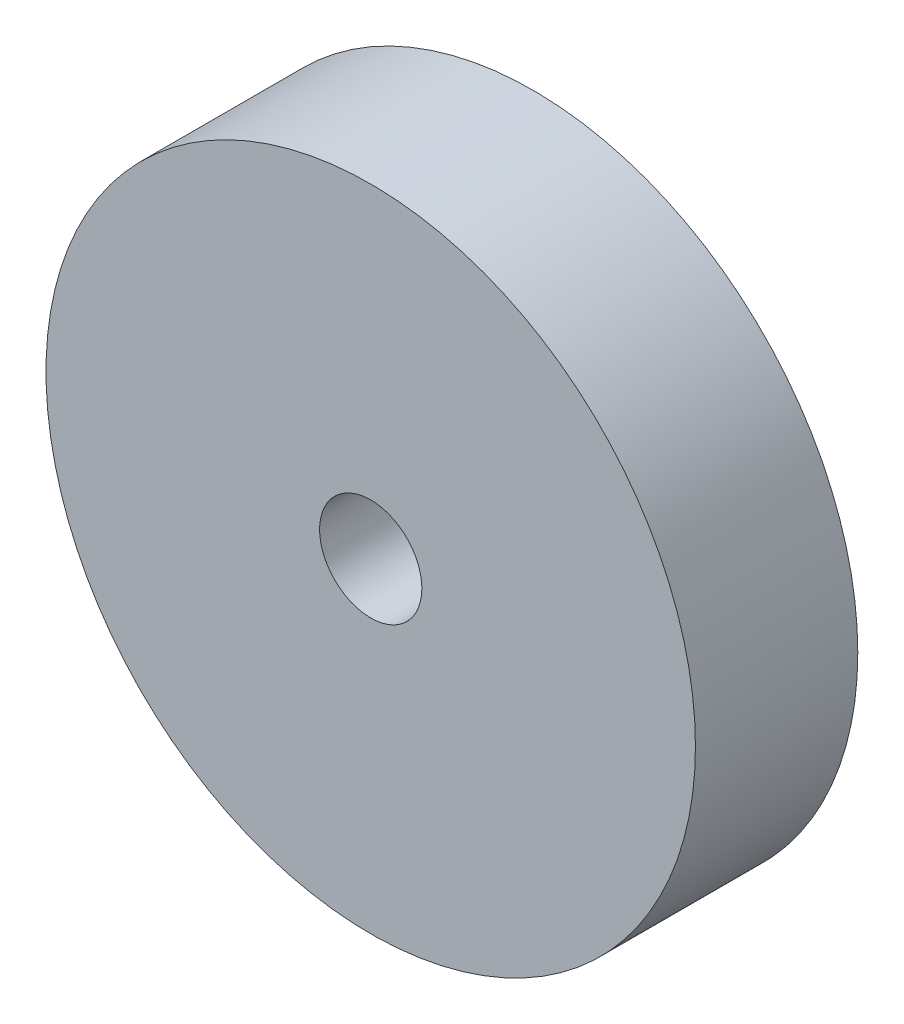
from build123d import *

# Parameters (mm, degrees)
SKETCH1_R           = 25.4
SKETCH1_R_2         = 4
BOSS_EXTRUDE1_DEPTH = 12.7


with BuildPart() as part:
    # Sketch1 → Boss-Extrude1 (new body)
    with BuildSketch(Plane.XY):
        Circle(SKETCH1_R)
        Circle(SKETCH1_R_2, mode=Mode.SUBTRACT)
    extrude(amount=BOSS_EXTRUDE1_DEPTH)


solid = part.part
